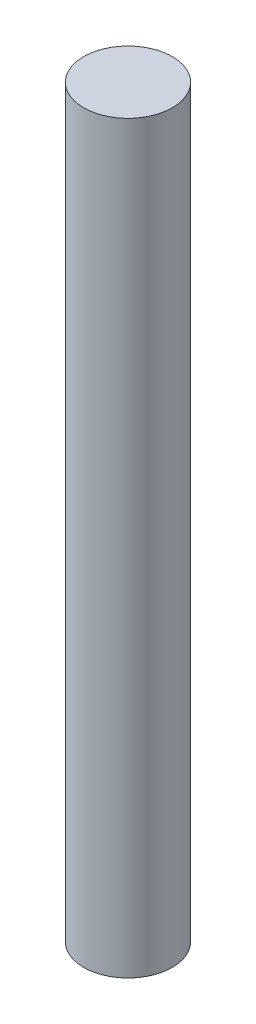
from build123d import *

# Parameters (mm, degrees)
SKETCH1_R                = 2.5
BOSS_EXTRUDE1_DEPTH      = 29
BOSS_EXTRUDE1_DEPTH_BACK = 13


with BuildPart() as part:
    # Sketch1 → Boss-Extrude1 (new body, two sides)
    with BuildSketch(Plane(origin=(0, 0, 0), x_dir=(1, 0, 0), z_dir=(0, 1, 0))) as boss_extrude1_sk:
        Circle(SKETCH1_R)
    extrude(amount=BOSS_EXTRUDE1_DEPTH)
    extrude(boss_extrude1_sk.sketch, amount=-BOSS_EXTRUDE1_DEPTH_BACK)


solid = part.part
